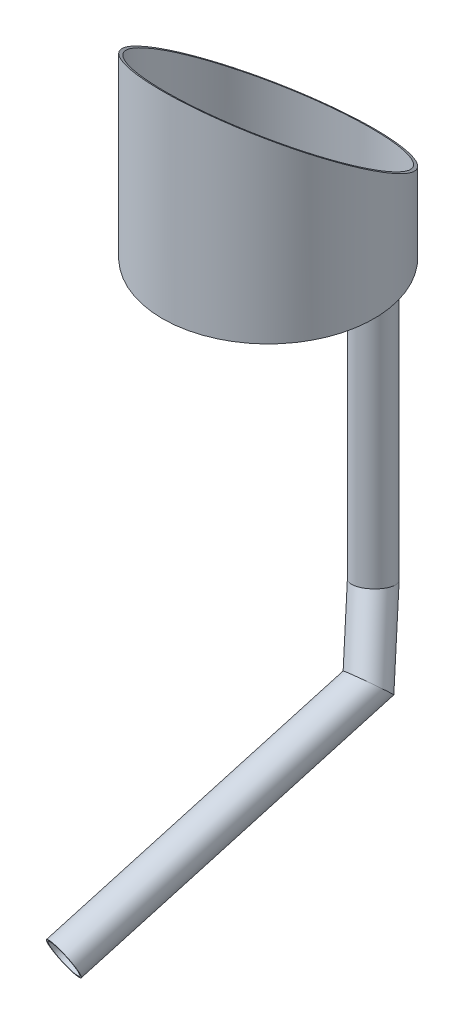
from build123d import *

# Parameters (mm, degrees)
SKETCH6_R                                      = 110
SKETCH6_R_2                                    = 8
SKETCH6_R_3                                    = 7.5
BOSS_EXTRUDE5_DEPTH                            = 5
SKETCH8_R                                      = 110
SKETCH8_R_2                                    = 107
BOSS_EXTRUDE6_DEPTH                            = 200
CUT_EXTRUDE1_DEPTH                             = 258.342184649
CUT_EXTRUDE1_DEPTH_BACK                        = 258.342184649
SKETCH11_R                                     = 25
SKETCH11_R_2                                   = 17.5
BOSS_EXTRUDE7_DEPTH                            = 25
SKETCH12_R                                     = 17.5
SKETCH12_R_2                                   = 15
BOSS_EXTRUDE8_DEPTH                            = 14
SKETCH13_W                                     = 4.337683853
SKETCH13_H                                     = 3.296654895
CUT_EXTRUDE2_DEPTH                             = 10
SKETCH1_R                                      = 19.05
SKETCH1_R_2                                    = 17.399
AL_ROUND_TUBING_AL_RND_TUBE_1_5_OD_X_0_0_DEPTH = 313.166024089
SKETCH1_ON_SEGMENT_2_R                         = 19.05
SKETCH1_ON_SEGMENT_2_R_2                       = 17.399
AL_ROUND_TUBING_AL_RND_TUBE_1_5_OD_X_3_DEPTH   = 97.201236225
SKETCH1_ON_SEGMENT_3_R                         = 19.05
SKETCH1_ON_SEGMENT_3_R_2                       = 17.399
AL_ROUND_TUBING_AL_RND_TUBE_1_5_OD_X_5_DEPTH   = 317.435212136


with BuildPart() as part:
    # Sketch6 → Boss-Extrude5 (new body)
    with BuildSketch(Plane(origin=(0, 0, 0), x_dir=(1, 0, 0), z_dir=(0, 1, 0))):
        with Locations(Location((0, 0, 0), (0, 0, 270))):
            Circle(SKETCH6_R)
        with Locations(Location((0, 0, 0), (0, 0, 270))):
            Circle(SKETCH6_R_2, mode=Mode.SUBTRACT)
        with Locations(Location((40, 69.282032303, 0), (0, 0, 270))):
            Circle(SKETCH6_R_3, mode=Mode.SUBTRACT)
    extrude(amount=BOSS_EXTRUDE5_DEPTH)

    # Sketch8 → Boss-Extrude6 (add)
    with BuildSketch(Plane(origin=(0, 5, 0), x_dir=(1, 0, 0), z_dir=(0, 1, 0))):
        with Locations(Location((0, 0, 0), (0, 0, 270))):
            Circle(SKETCH8_R)
        with Locations(Location((0, 0, 0), (0, 0, 270))):
            Circle(SKETCH8_R_2, mode=Mode.SUBTRACT)
    extrude(amount=BOSS_EXTRUDE6_DEPTH)

    # Sketch10 → Cut-Extrude1 (cut, two sides)
    with BuildSketch(Plane(origin=(0, 0, 0), x_dir=(0, 0, -1), z_dir=(1, 0, 0))) as cut_extrude1_sk:
        Polygon((-110, 205), (110, 61.286460946), (110, 205), align=None)
    extrude(amount=CUT_EXTRUDE1_DEPTH, mode=Mode.SUBTRACT)
    extrude(cut_extrude1_sk.sketch, amount=-CUT_EXTRUDE1_DEPTH_BACK, mode=Mode.SUBTRACT)

    # Sketch11 → Boss-Extrude7 (add)
    with BuildSketch(Plane.XZ):
        with Locations(Location((0, 0, 0), (0, 0, 90))):
            Circle(SKETCH11_R)
        with Locations(Location((0, 0, 0), (0, 0, 270))):
            Circle(SKETCH11_R_2, mode=Mode.SUBTRACT)
    extrude(amount=BOSS_EXTRUDE7_DEPTH)

    # Sketch12 → Boss-Extrude8 (add)
    with BuildSketch(Plane.XZ):
        with Locations(Location((0, 0, 0), (0, 0, 270))):
            Circle(SKETCH12_R)
        with Locations(Location((0, 0, 0), (0, 0, 270))):
            Circle(SKETCH12_R_2, mode=Mode.SUBTRACT)
    extrude(amount=BOSS_EXTRUDE8_DEPTH)

    # Sketch13 → Cut-Extrude2 (cut)
    with BuildSketch(Plane.XZ):
        with Locations((45.296232559, -63.971672552)):
            Rectangle(SKETCH13_W, SKETCH13_H)
    extrude(amount=-CUT_EXTRUDE2_DEPTH, mode=Mode.SUBTRACT)


with BuildPart() as body_2:
    # Sketch1 → Al round tubing AL RND TUBE 1.5 OD X 0.063 WALL(7) (new body)
    with BuildSketch(Plane(origin=(40, 0, -69.282032303), x_dir=(1, 0, 0), z_dir=(0, -1, 0))):
        Circle(SKETCH1_R)
        Circle(SKETCH1_R_2, mode=Mode.SUBTRACT)
    extrude(amount=AL_ROUND_TUBING_AL_RND_TUBE_1_5_OD_X_0_0_DEPTH)

    # Al round tubing AL RND TUBE 1.5 OD X 2
    split(bisect_by=Plane(origin=(40, -304.8, -69.282032303), x_dir=(-0.985025258, -0.172410096, 0), z_dir=(-0.168834183, 0.964595101, -0.202611229)), keep=Keep.TOP)


with BuildPart() as body_3:
    # Sketch1 on segment 2 (carried to segment 2) → Al round tubing AL RND TUBE 1.5 OD X 3 (new body)
    with BuildSketch(Plane(origin=(37.275075097, -297.597795128, -72.552106968), x_dir=(0.942990038, 0.325713251, -0.068415402), z_dir=(0.325713251, -0.860887417, 0.390875598))):
        Circle(SKETCH1_ON_SEGMENT_2_R)
        Circle(SKETCH1_ON_SEGMENT_2_R_2, mode=Mode.SUBTRACT)
    extrude(amount=AL_ROUND_TUBING_AL_RND_TUBE_1_5_OD_X_3_DEPTH)

    # Al round tubing AL RND TUBE 1.5 OD X 3 m
    split(bisect_by=Plane(origin=(40, -304.8, -69.282032303), x_dir=(0.985025258, 0.172410096, 0), z_dir=(0.168834183, -0.964595101, 0.202611229)), keep=Keep.TOP)

    # Al round tubing AL RND TUBE 1.5 OD X 4
    split(bisect_by=Plane(origin=(64.819349716, -370.399621206, -39.497311768), x_dir=(-0.993524923, -0.113614379, 0), z_dir=(-0.082820389, 0.724240375, -0.684555814)), keep=Keep.TOP)


with BuildPart() as body_4:
    # Sketch1 on segment 3 (carried to segment 3) → Al round tubing AL RND TUBE 1.5 OD X 5 (new body)
    with BuildSketch(Plane(origin=(67.013431278, -364.475251828, -50.43972646), x_dir=(0.979471613, -0.173648178, 0.102380022), z_dir=(-0.173648178, -0.468877714, 0.866025404))):
        Circle(SKETCH1_ON_SEGMENT_3_R)
        Circle(SKETCH1_ON_SEGMENT_3_R_2, mode=Mode.SUBTRACT)
    extrude(amount=AL_ROUND_TUBING_AL_RND_TUBE_1_5_OD_X_5_DEPTH)

    # Al round tubing AL RND TUBE 1.5 OD X 5 m
    split(bisect_by=Plane(origin=(64.819349716, -370.399621206, -39.497311768), x_dir=(0.993524923, 0.113614379, 0), z_dir=(0.082820389, -0.724240375, 0.684555814)), keep=Keep.TOP)


solid = Compound([part.part, body_2.part, body_3.part, body_4.part])
